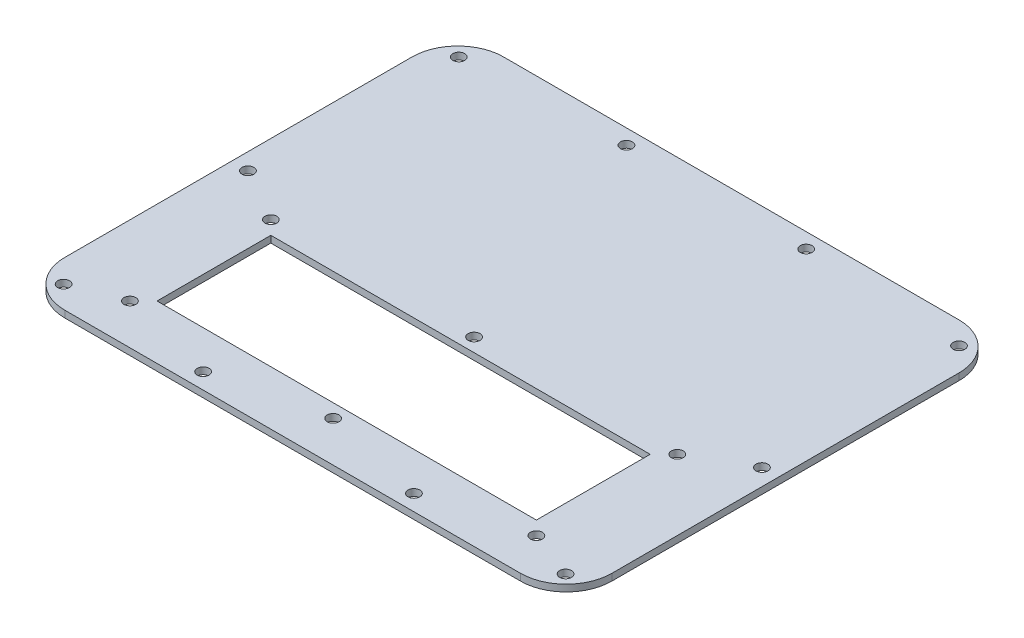
from build123d import *

# Parameters (mm, degrees)
SKETCH2_R           = 2.7813
BOSS_EXTRUDE1_DEPTH = 3.175
SKETCH3_W           = 177.8
SKETCH3_H           = 53.34
CUT_EXTRUDE1_DEPTH  = 3.175
SKETCH4_R           = 2.7813
CUT_EXTRUDE2_DEPTH  = 3.175


with BuildPart() as part:
    # Sketch2 → Boss-Extrude1 (new body)
    with BuildSketch(Plane(origin=(0, 0, 0), x_dir=(1, 0, 0), z_dir=(0, 1, 0))):
        with BuildLine():
            Line((-106.7689, -102.8065), (106.7689, -102.8065))
            ThreePointArc((106.7689, -102.8065), (121.927572332, -96.527572332), (128.2065, -81.3689))
            Line((128.2065, -81.3689), (128.2065, 81.3689))
            ThreePointArc((128.2065, 81.3689), (121.927572332, 96.527572332), (106.7689, 102.8065))
            Line((106.7689, 102.8065), (-106.7689, 102.8065))
            ThreePointArc((-106.7689, 102.8065), (-121.927572332, 96.527572332), (-128.2065, 81.3689))
            Line((-128.2065, 81.3689), (-128.2065, -81.3689))
            ThreePointArc((-128.2065, -81.3689), (-121.927572332, -96.527572332), (-106.7689, -102.8065))
        make_face()
        with Locations((42.1132, 95.7453)):
            Circle(SKETCH2_R, mode=Mode.SUBTRACT)
        with Locations((117.221, 92.2909)):
            Circle(SKETCH2_R, mode=Mode.SUBTRACT)
        with Locations((120.4468, -3.3147)):
            Circle(SKETCH2_R, mode=Mode.SUBTRACT)
        with Locations((117.6274, -92.5195)):
            Circle(SKETCH2_R, mode=Mode.SUBTRACT)
        with Locations((49.403, -95.3643)):
            Circle(SKETCH2_R, mode=Mode.SUBTRACT)
        with Locations((-49.403, -95.3643)):
            Circle(SKETCH2_R, mode=Mode.SUBTRACT)
        with Locations((-117.6274, -92.5195)):
            Circle(SKETCH2_R, mode=Mode.SUBTRACT)
        with Locations((-120.4468, -3.3147)):
            Circle(SKETCH2_R, mode=Mode.SUBTRACT)
        with Locations((-117.221, 92.2909)):
            Circle(SKETCH2_R, mode=Mode.SUBTRACT)
        with Locations((-42.1132, 95.7453)):
            Circle(SKETCH2_R, mode=Mode.SUBTRACT)
    extrude(amount=BOSS_EXTRUDE1_DEPTH)

    # Sketch3 → Cut-Extrude1 (cut)
    with BuildSketch(Plane(origin=(0, 0, 0), x_dir=(1, 0, 0), z_dir=(0, 1, 0))):
        with Locations((0, -50.8)):
            Rectangle(SKETCH3_W, SKETCH3_H)
    extrude(amount=CUT_EXTRUDE1_DEPTH, mode=Mode.SUBTRACT)

    # Sketch4 → Cut-Extrude2 (cut)
    with BuildSketch(Plane(origin=(0, 0, 0), x_dir=(1, 0, 0), z_dir=(0, 1, 0))):
        with Locations((-95.25, -17.78)):
            Circle(SKETCH4_R)
        with Locations((0, -17.78)):
            Circle(SKETCH4_R)
        with Locations((95.25, -17.78)):
            Circle(SKETCH4_R)
        with Locations((95.25, -83.82)):
            Circle(SKETCH4_R)
        with Locations((0, -83.82)):
            Circle(SKETCH4_R)
        with Locations((-95.25, -83.82)):
            Circle(SKETCH4_R)
    extrude(amount=CUT_EXTRUDE2_DEPTH, mode=Mode.SUBTRACT)


solid = part.part
